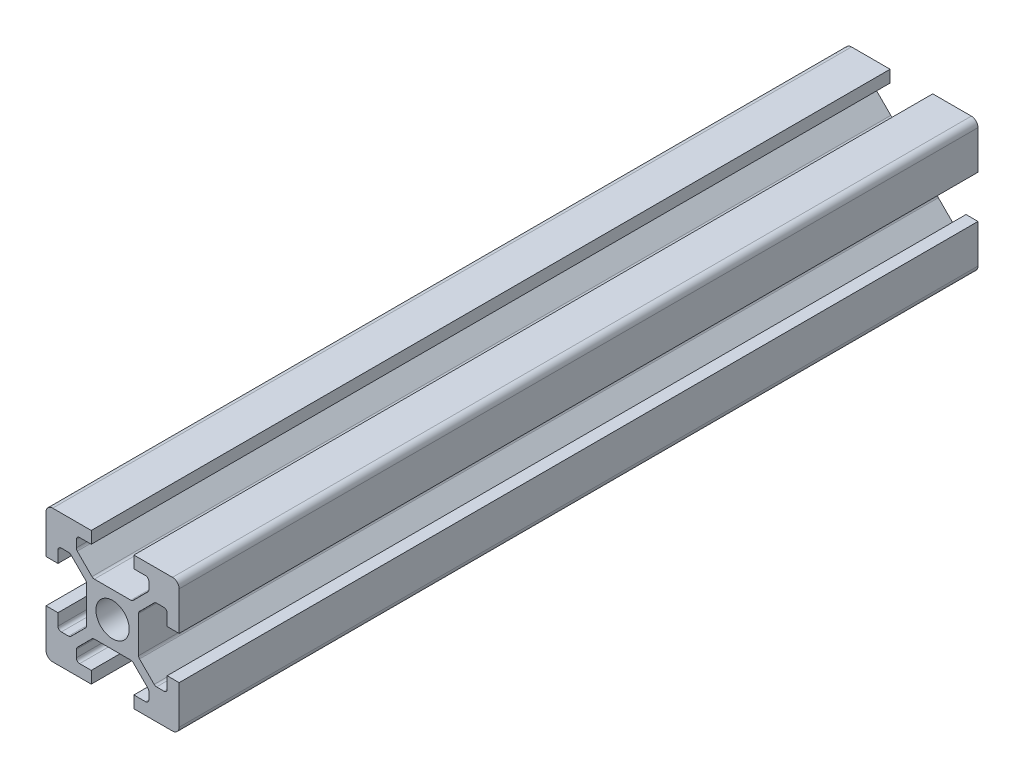
from build123d import *

# Parameters (mm, degrees)
SKETCH1_R           = 2.5
BOSS_EXTRUDE1_DEPTH = 120
FILLET1_R           = 1
FILLET2_R           = 0.5
FILLET3_R           = 0.5
FILLET4_R           = 0.5
FILLET5_R           = 0.5
SKETCH2_R           = 2.5
CUT_EXTRUDE1_DEPTH  = 8


with BuildPart() as part:
    # Sketch1 → Boss-Extrude1 (new body)
    with BuildSketch(Plane.XY):
        Polygon((13.2, 0), (13.2, 1.8), (15.45, 1.8), (15.45, 3.6), (12.95, 6.1), (7.05, 6.1), (4.55, 3.6), (4.55, 1.8), (6.8, 1.8), (6.8, 0), (0, 0), (0, 6.8), (1.8, 6.8), (1.8, 4.55), (3.6, 4.55), (6.1, 7.05), (6.1, 12.95), (3.6, 15.45), (1.8, 15.45), (1.8, 13.2), (0, 13.2), (0, 20), (6.8, 20), (6.8, 18.2), (4.55, 18.2), (4.55, 16.4), (7.05, 13.9), (12.95, 13.9), (15.45, 16.4), (15.45, 18.2), (13.2, 18.2), (13.2, 20), (20, 20), (20, 13.2), (18.2, 13.2), (18.2, 15.45), (16.4, 15.45), (13.9, 12.95), (13.9, 7.05), (16.4, 4.55), (18.2, 4.55), (18.2, 6.8), (20, 6.8), (20, 0), align=None)
        with Locations((10, 10)):
            Circle(SKETCH1_R, mode=Mode.SUBTRACT)
    extrude(amount=BOSS_EXTRUDE1_DEPTH)

    # Fillet1
    fillet1_edges = [part.edges().sort_by_distance(p)[0] for p in [
        (0, 0, 60),
        (0, 20, 60),
        (20, 20, 60),
        (20, 0, 60),
    ]]
    fillet(fillet1_edges, radius=FILLET1_R)

    # Fillet2
    fillet2_edges = [part.edges().sort_by_distance(p)[0] for p in [
        (4.55, 18.2, 60),
        (4.55, 16.4, 60),
        (7.05, 13.9, 60),
        (12.95, 13.9, 60),
        (15.45, 16.4, 60),
        (15.45, 18.2, 60),
    ]]
    fillet(fillet2_edges, radius=FILLET2_R)

    # Fillet3
    fillet3_edges = [part.edges().sort_by_distance(p)[0] for p in [
        (18.2, 15.45, 60),
        (16.4, 15.45, 60),
        (13.9, 12.95, 60),
        (13.9, 7.05, 60),
        (16.4, 4.55, 60),
        (18.2, 4.55, 60),
    ]]
    fillet(fillet3_edges, radius=FILLET3_R)

    # Fillet4
    fillet4_edges = [part.edges().sort_by_distance(p)[0] for p in [
        (1.8, 4.55, 60),
        (3.6, 4.55, 60),
        (6.1, 7.05, 60),
        (6.1, 12.95, 60),
        (3.6, 15.45, 60),
        (1.8, 15.45, 60),
    ]]
    fillet(fillet4_edges, radius=FILLET4_R)

    # Fillet5
    fillet5_edges = [part.edges().sort_by_distance(p)[0] for p in [
        (15.45, 1.8, 60),
        (15.45, 3.6, 60),
        (12.95, 6.1, 60),
        (7.05, 6.1, 60),
        (4.55, 3.6, 60),
        (4.55, 1.8, 60),
    ]]
    fillet(fillet5_edges, radius=FILLET5_R)

    # Sketch2 → Cut-Extrude1 (cut)
    with BuildSketch(Plane(origin=(0, 13.9, 0), x_dir=(1, 0, 0), z_dir=(0, 1, 0))):
        with Locations((10, -60)):
            Circle(SKETCH2_R)
        with Locations((10, -80)):
            Circle(SKETCH2_R)
        with Locations((10, -40)):
            Circle(SKETCH2_R)
    extrude(amount=-CUT_EXTRUDE1_DEPTH, mode=Mode.SUBTRACT)


solid = part.part
